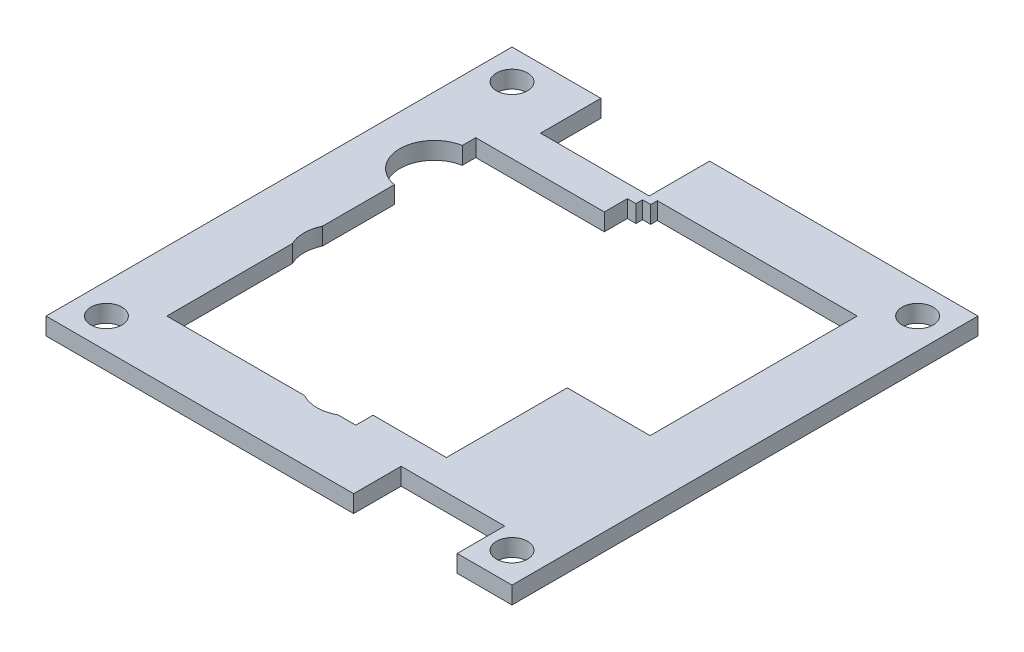
from build123d import *

# Parameters (mm, degrees)
SKETCH_3_R      = 1.8
SKETCH_3_W      = 0.8
SKETCH_3_H      = 1.5
SKETCH_3_W_2    = 1
SKETCH_3_W_3    = 0.944853381
SKETCH_3_H_2    = 0.76832805
EXTRUDE_2_DEPTH = 2


with BuildPart() as part:
    # 草图3 → 凸台-拉伸2 (new body)
    with BuildSketch(Plane(origin=(0, 0, 0), x_dir=(1, 0, 0), z_dir=(0, 1, 0))):
        with BuildLine():
            Line((8.65, -27), (8.65, -21.5))
            Line((8.65, -21.5), (8.65, -20))
            Line((8.65, -20), (1.9, -20))
            Line((1.9, -20), (-0.163508327, -20))
            ThreePointArc((-0.163508327, -20), (-2.1, -20.5), (-4.036491673, -20))
            Line((-4.036491673, -20), (-20, -20))
            Line((-20, -20), (-20, -5.443559577))
            ThreePointArc((-20, -5.443559577), (-20.4, -3.7), (-20, -1.956440423))
            Line((-20, -1.956440423), (-20, 6.361726266))
            ThreePointArc((-20, 6.361726266), (-23.3, 10.3), (-20, 14.238273734))
            Line((-20, 14.238273734), (-20, 15.8))
            Line((-20, 15.8), (-20, 20))
            Line((-20, 20), (-16.7, 20))
            Line((-16.7, 20), (-16.7, 27))
            Line((-16.7, 27), (-27, 27))
            Line((-27, 27), (-27, -27))
            Line((-27, -27), (8.65, -27))
        make_face()
        with Locations((-23.5, -23.5)):
            Circle(SKETCH_3_R, mode=Mode.SUBTRACT)
        with Locations((-23.5, 23.5)):
            Circle(SKETCH_3_R, mode=Mode.SUBTRACT)
        Polygon((20, -18), (20, -20), (20.65, -20), (20.65, -21.5), (20.65, -27), (27, -27), (27, 27), (-4.1, 27), (-4.1, 20), (-3.155146619, 20), (20, 20), (20, -4), align=None)
        with Locations((23.5, -23.5)):
            Circle(SKETCH_3_R, mode=Mode.SUBTRACT)
        with Locations((23.5, 23.5)):
            Circle(SKETCH_3_R, mode=Mode.SUBTRACT)
        Polygon((12.4, -20), (12.4, -19.5), (12.4, -18), (10.4, -18), (1.9, -18), (1.9, -20), (8.65, -20), align=None)
        Polygon((20, -20), (16.9, -20), (16.9, -19.5), (16.1, -19.5), (13.4, -19.5), (12.4, -19.5), (12.4, -20), (8.65, -20), (8.65, -21.5), (20.65, -21.5), (20.65, -20), align=None)
        Polygon((16.9, -19.5), (16.9, -20), (20, -20), (20, -18), (16.9, -18), align=None)
        with Locations((16.5, -18.75)):
            Rectangle(SKETCH_3_W, SKETCH_3_H)
        with Locations((12.9, -18.75)):
            Rectangle(SKETCH_3_W_2, SKETCH_3_H)
        Polygon((16.1, -18), (16.9, -18), (16.9, -6), (12.4, -6), (12.4, -18), (13.4, -18), (13.4, -19.5), (16.1, -19.5), align=None)
        Polygon((16.9, -18), (20, -18), (20, -4), (10.4, -4), (10.4, -6), (10.4, -18), (12.4, -18), (12.4, -6), (16.9, -6), align=None)
        with Locations((-3.62757331, 19.615835975)):
            Rectangle(SKETCH_3_W_3, SKETCH_3_H_2)
        Polygon((-4.1, 19.23167195), (-4.1, 20), (-10.4, 20), (-16.7, 20), (-20, 20), (-20, 15.8), (-5.1, 15.8), (-5.1, 18.463343901), (-4.1, 18.463343901), align=None)
    extrude(amount=EXTRUDE_2_DEPTH)


solid = part.part
